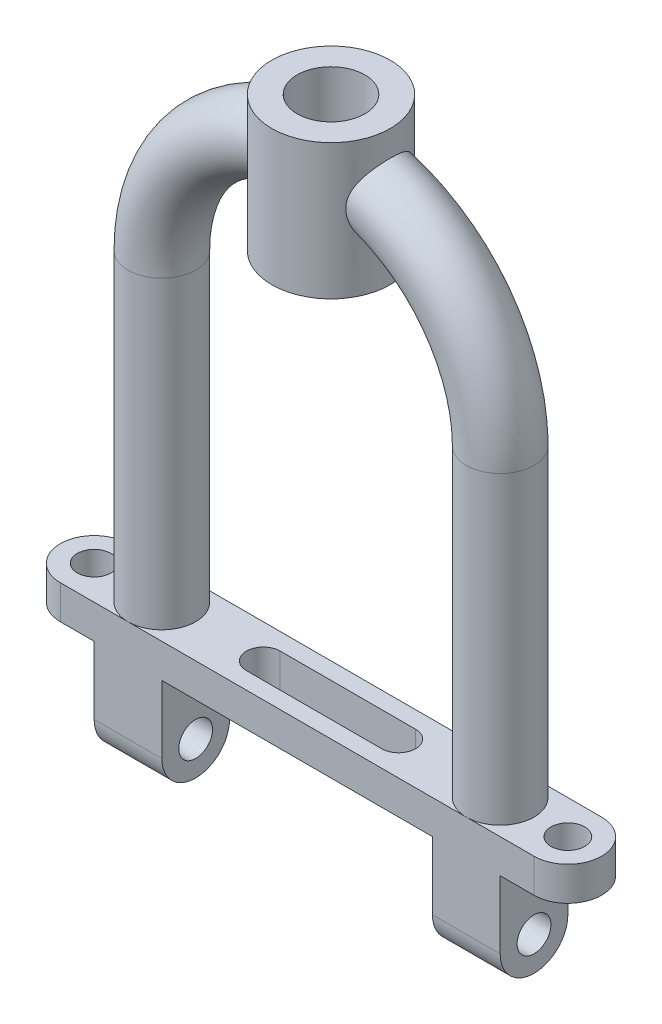
from build123d import *

# Parameters (mm, degrees)
ESBO_O1_R                = 0.25
RESSALTO_EXTRUS_O1_DEPTH = 0.25
ESBO_O2_R                = 0.5
ESBO_O5_R                = 0.25
RESSALTO_EXTRUS_O2_DEPTH = 0.5
ESBO_O6_R                = 0.875
RESSALTO_EXTRUS_O3_DEPTH = 2
ESBO_O7_R                = 0.5
CORTE_EXTRUS_O1_DEPTH    = 2


with BuildPart() as part:
    # Esboço1 → Ressalto-extrusão1 (new body, symmetric)
    with BuildSketch(Plane(origin=(0, 0, 0), x_dir=(1, 0, 0), z_dir=(0, 1, 0))):
        with BuildLine():
            Line((-3.5, 0.5), (3.5, 0.5))
            ThreePointArc((3.5, 0.5), (4, 0), (3.5, -0.5))
            Line((3.5, -0.5), (-3.5, -0.5))
            ThreePointArc((-3.5, -0.5), (-4, 0), (-3.5, 0.5))
        make_face()
        with Locations((3.5, 0)):
            Circle(ESBO_O1_R, mode=Mode.SUBTRACT)
        with Locations((-3.5, 0)):
            Circle(ESBO_O1_R, mode=Mode.SUBTRACT)
        with BuildLine():
            Line((-1, 0.25), (1, 0.25))
            ThreePointArc((1, 0.25), (1.25, 0), (1, -0.25))
            Line((1, -0.25), (-1, -0.25))
            ThreePointArc((-1, -0.25), (-1.25, 0), (-1, 0.25))
        make_face(mode=Mode.SUBTRACT)
    extrude(amount=RESSALTO_EXTRUS_O1_DEPTH, both=True)

    # Varredura1: sweep along a path in Esboço3
    with BuildLine(Plane.XY) as varredura1_path:
        Line((-2.5, 0.25), (-2.5, 4.75))
        ThreePointArc((-2.5, 4.75), (0, 7.25), (2.5, 4.75))
        Line((2.5, 4.75), (2.5, 0.25))
    # Esboço2 → Varredura1 (sweep)
    with BuildSketch(Plane(origin=(0, 0.25, 0), x_dir=(1, 0, 0), z_dir=(0, 1, 0))):
        with Locations((-2.5, 0)):
            Circle(ESBO_O2_R)
    sweep(path=varredura1_path.line)

    # Esboço5 → Ressalto-extrusão2 (add, symmetric)
    with BuildSketch(Plane(origin=(-2.5, 0, 0), x_dir=(0, 0, -1), z_dir=(1, 0, 0))):
        with BuildLine():
            Line((0.5, -0.25), (-0.5, -0.25))
            Line((-0.5, -0.25), (-0.5, -1.25))
            ThreePointArc((-0.5, -1.25), (0, -1.75), (0.5, -1.25))
            Line((0.5, -1.25), (0.5, -0.25))
        make_face()
        with Locations((0, -1.25)):
            Circle(ESBO_O5_R, mode=Mode.SUBTRACT)
    ressalto_extrus_o2 = extrude(amount=RESSALTO_EXTRUS_O2_DEPTH, both=True)

    # Espelhar1: Ressalto-extrusão2 across plane
    add(ressalto_extrus_o2.mirror(Plane(origin=(0, 0, 0), x_dir=(0, 0, 1), z_dir=(1, 0, 0))))

    # Esboço6 → Ressalto-extrusão3 (add)
    with BuildSketch(Plane(origin=(0, 6, 0), x_dir=(1, 0, 0), z_dir=(0, 1, 0))):
        Circle(ESBO_O6_R)
    extrude(amount=RESSALTO_EXTRUS_O3_DEPTH)

    # Esboço7 → Corte-extrusão1 (cut)
    with BuildSketch(Plane(origin=(0, 8, 0), x_dir=(1, 0, 0), z_dir=(0, 1, 0))):
        Circle(ESBO_O7_R)
    extrude(amount=-CORTE_EXTRUS_O1_DEPTH, mode=Mode.SUBTRACT)


solid = part.part
